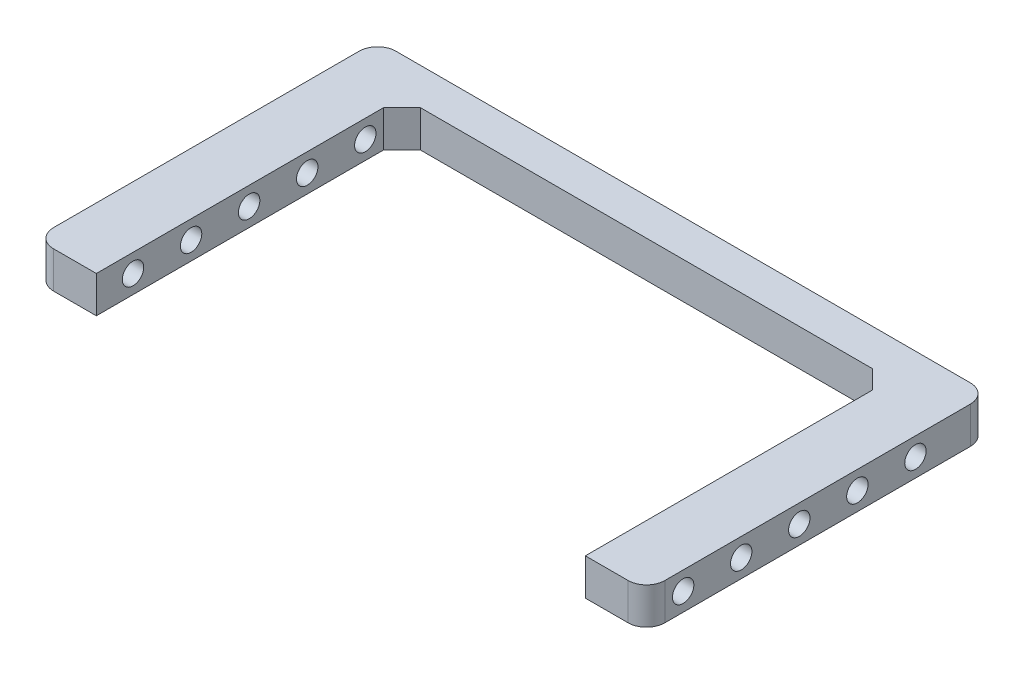
from build123d import *

# Parameters (mm, degrees)
BOSS_EXTRUDE1_DEPTH     = 3
SKETCH2_R               = 0.875
CUT_EXTRUDE1_DEPTH      = 51
CUT_EXTRUDE1_DEPTH_BACK = 3
FILLET2_R               = 1.5
CHAMFER1_SIZE           = 1.5


with BuildPart() as part:
    # Sketch1 → Boss-Extrude1 (new body)
    with BuildSketch(Plane(origin=(0, 0, 0), x_dir=(1, 0, 0), z_dir=(0, 1, 0))):
        Polygon((-25, -14), (-20, -14), (-20, 11), (20, 11), (20, -14), (25, -14), (25, 14), (-25, 14), align=None)
    extrude(amount=BOSS_EXTRUDE1_DEPTH)

    # Sketch2 → Cut-Extrude1 (cut, two sides)
    with BuildSketch(Plane.ZY.offset(-25)) as cut_extrude1_sk:
        with Locations((11, 1.5)):
            Circle(SKETCH2_R)
        with Locations((6.25, 1.5)):
            Circle(SKETCH2_R)
        with Locations((1.5, 1.5)):
            Circle(SKETCH2_R)
        with Locations((-3.25, 1.5)):
            Circle(SKETCH2_R)
        with Locations((-8, 1.5)):
            Circle(SKETCH2_R)
    extrude(amount=CUT_EXTRUDE1_DEPTH, mode=Mode.SUBTRACT)
    extrude(cut_extrude1_sk.sketch, amount=-CUT_EXTRUDE1_DEPTH_BACK, mode=Mode.SUBTRACT)

    # Fillet2
    fillet2_edges = [part.edges().sort_by_distance(p)[0] for p in [
        (25, 1.5, 14),
        (-25, 1.5, 14),
        (-25, 1.5, -14),
        (25, 1.5, -14),
    ]]
    fillet(fillet2_edges, radius=FILLET2_R)

    # Chamfer1
    chamfer1_edges = [part.edges().sort_by_distance(p)[0] for p in [
        (20, 1.5, -11),
        (-20, 1.5, -11),
    ]]
    chamfer(chamfer1_edges, length=CHAMFER1_SIZE)


solid = part.part
